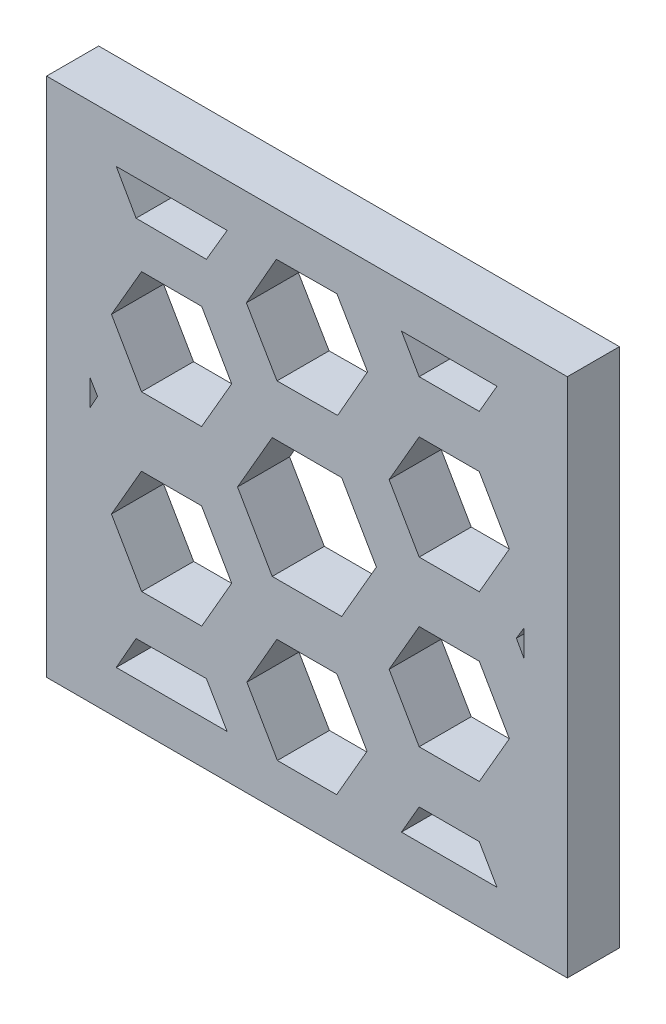
from build123d import *

# Parameters (mm, degrees)
SALIENTE_EXTRUIR3_DEPTH = 3


with BuildPart() as part:
    # Croquis1 → Saliente-Extruir3 (new body)
    with BuildSketch(Plane.XY):
        Polygon((-11.260603559, 15), (-15, 15), (-15, 3.468631071), (-15, -2.593220906), (-15, -15), (15, -15), (15, 15), (10.926682634, 15), (5.464101822, 15), (-4.343979365, 15), align=None)
        Polygon((-4.598156154, -12.5), (-10.987751023, -12.5), (-9.843926146, -10.486593018), (-5.795898544, -10.458408789), align=None, mode=Mode.SUBTRACT)
        Polygon((-1.735474056, -6.470030855), (1.725204311, -6.464101615), (3.460678367, -9.458172375), (2.574022478, -11), (1.788213156, -12.366463064), (1.735474056, -12.458172375), (1.711420323, -12.5), (-1.70439628, -12.5), (-1.725204311, -12.464101615), (-2.573851712, -11), (-3.460678367, -9.470030855), align=None, mode=Mode.SUBTRACT)
        Polygon((-9.52712635, -7.980422404), (-11, -5.43688968), (-11.262605478, -4.983391428), (-11, -4.527191603), (-9.53484008, -1.981906927), (-6.071595554, -1.977453403), (-4.336116426, -4.974484379), (-6.063881824, -7.97596888), align=None, mode=Mode.SUBTRACT)
        Polygon((10.94791539, -12.5), (5.442868782, -12.5), (6.463594896, -10.732050867), (9.927189585, -10.732050867), align=None, mode=Mode.SUBTRACT)
        Polygon((2, 3.464101615), (4, 0), (2, -3.464101615), (-2, -3.464101615), (-4, 0), (-2, 3.464101615), align=None, mode=Mode.SUBTRACT)
        Polygon((9.928710122, -1.732928769), (10.635389239, -2.957649744), (11, -3.589543959), (11.659747147, -4.732928769), (11, -5.874975703), (10.463594724, -6.803513255), (9.927189448, -7.732050808), (6.463594724, -7.731172846), (4.732557699, -4.731172846), (5.598456213, -3.232270202), (6.465115398, -1.732050808), align=None, mode=Mode.SUBTRACT)
        Polygon((-12.064918104, 0.484419433), (-12.5, -0.297648548), (-12.5, 1.211047664), align=None, mode=Mode.SUBTRACT)
        Polygon((-9.52712635, 7.980422404), (-6.063881824, 7.97596888), (-4.336116426, 4.974484379), (-6.071595554, 1.977453403), (-9.53484008, 1.981906927), (-10.26742004, 3.254549265), (-10.460255366, 3.589543959), (-10.62999033, 3.884408567), (-11, 4.527191603), (-11.262605478, 4.983391428), (-11, 5.43688968), (-10.401742938, 6.470030855), align=None, mode=Mode.SUBTRACT)
        Polygon((-9.843926146, 10.486593018), (-10.987751023, 12.5), (-4.598156154, 12.5), (-5.795898544, 10.458408789), align=None, mode=Mode.SUBTRACT)
        Polygon((1.725204311, 12.5), (2.604960918, 11), (3.49176728, 9.487980048), (1.766562969, 6.452081663), (-1.725204311, 6.42820323), (-3.49176728, 9.440223182), (-2.605395818, 11), (-1.766562969, 12.476121567), align=None, mode=Mode.SUBTRACT)
        Polygon((12.5, 1.211047664), (12.5, -0.297648548), (12.064918104, 0.484419433), align=None, mode=Mode.SUBTRACT)
        Polygon((11, 3.589543959), (9.928710122, 1.732928769), (6.465115398, 1.732050808), (4.732557699, 4.731172846), (6.463594724, 7.731172846), (9.927189448, 7.732050808), (11, 5.874975703), (11.659747147, 4.732928769), align=None, mode=Mode.SUBTRACT)
        Polygon((6.463594896, 10.732050808), (5.442868954, 12.5), (10.947915528, 12.5), (9.927189585, 10.732050808), align=None, mode=Mode.SUBTRACT)
    extrude(amount=SALIENTE_EXTRUIR3_DEPTH)


solid = part.part
